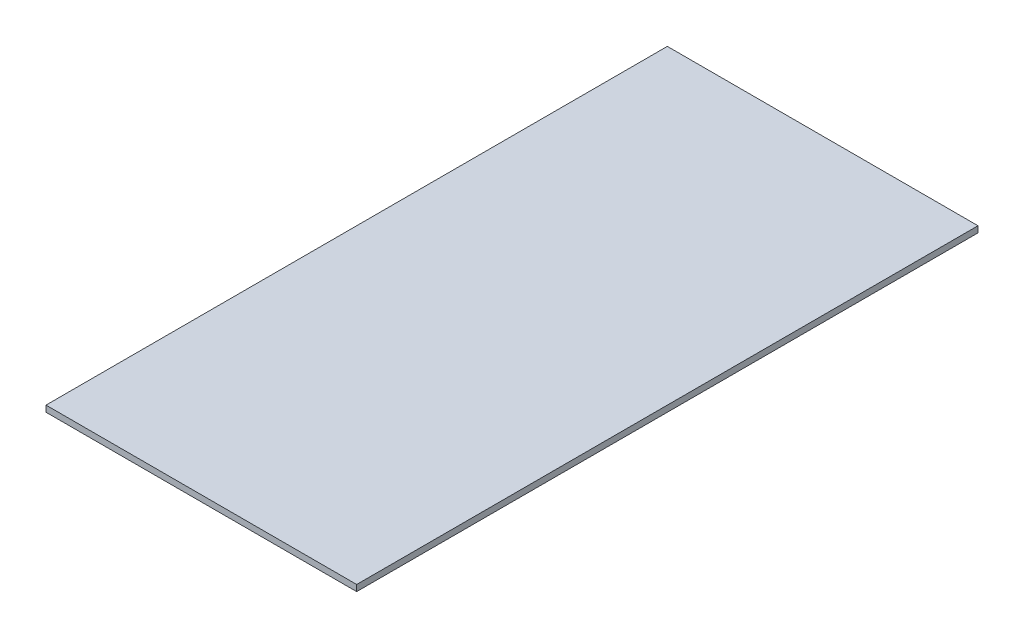
from build123d import *

# Parameters (mm, degrees)
SKETCH1_W           = 200
SKETCH1_H           = 400
BOSS_EXTRUDE1_DEPTH = 4


with BuildPart() as part:
    # Sketch1 → Boss-Extrude1 (new body)
    with BuildSketch(Plane(origin=(0, 0, 0), x_dir=(1, 0, 0), z_dir=(0, 1, 0))):
        with Locations((0, 49.488739603)):
            Rectangle(SKETCH1_W, SKETCH1_H)
    extrude(amount=BOSS_EXTRUDE1_DEPTH)


solid = part.part
